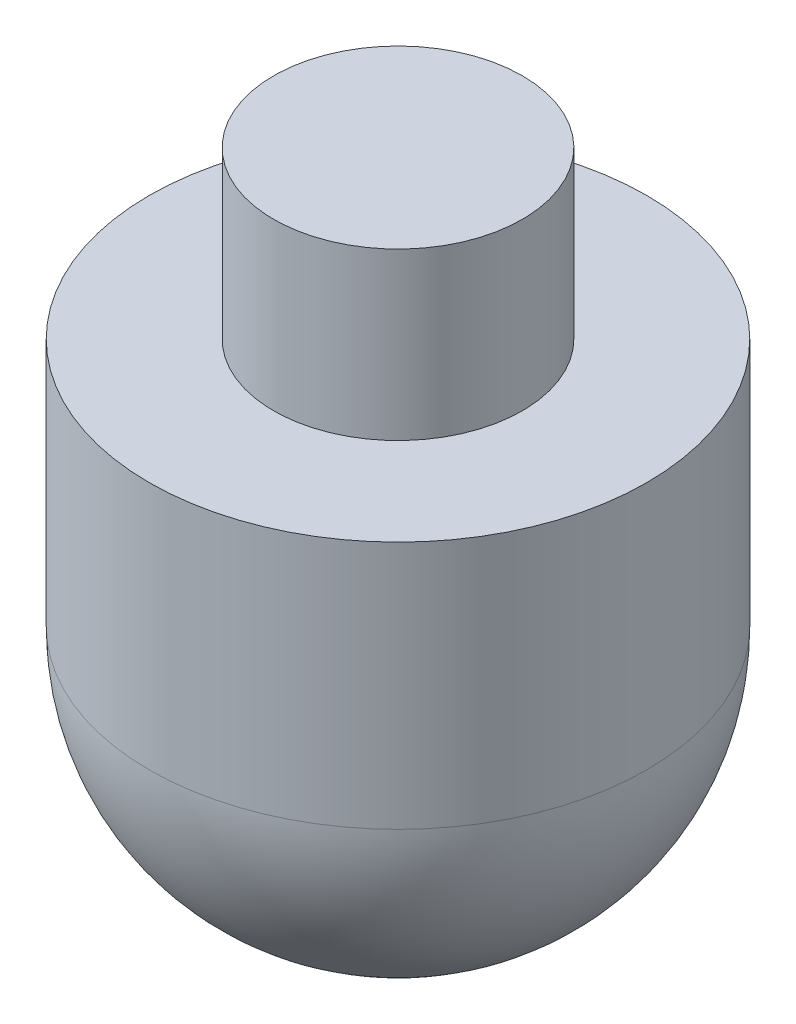
from build123d import *

# Parameters (mm, degrees)
FILLET1_R = 15


with BuildPart() as part:
    # Sketch1 → Revolve1 (revolve)
    with BuildSketch(Plane.XY, mode=Mode.PRIVATE) as revolve1_sk:
        Polygon((0, 41.704901462), (7.5, 41.704901462), (7.5, 31.704901462), (15, 31.704901462), (15, 1.704901462), (0, 1.704901462), align=None)
    revolve(revolve1_sk.sketch.rotate(Axis((0, 1.704901462, 0), (0, 1, 0)), 90), axis=Axis((0, 1.704901462, 0), (0, 1, 0)))  # turned: the seam where the file's is

    # Fillet1
    fillet1_edges = [part.edges().sort_by_distance(p)[0] for p in [
        (0, 1.704901462, 15),
    ]]
    fillet(fillet1_edges, radius=FILLET1_R)


solid = part.part
